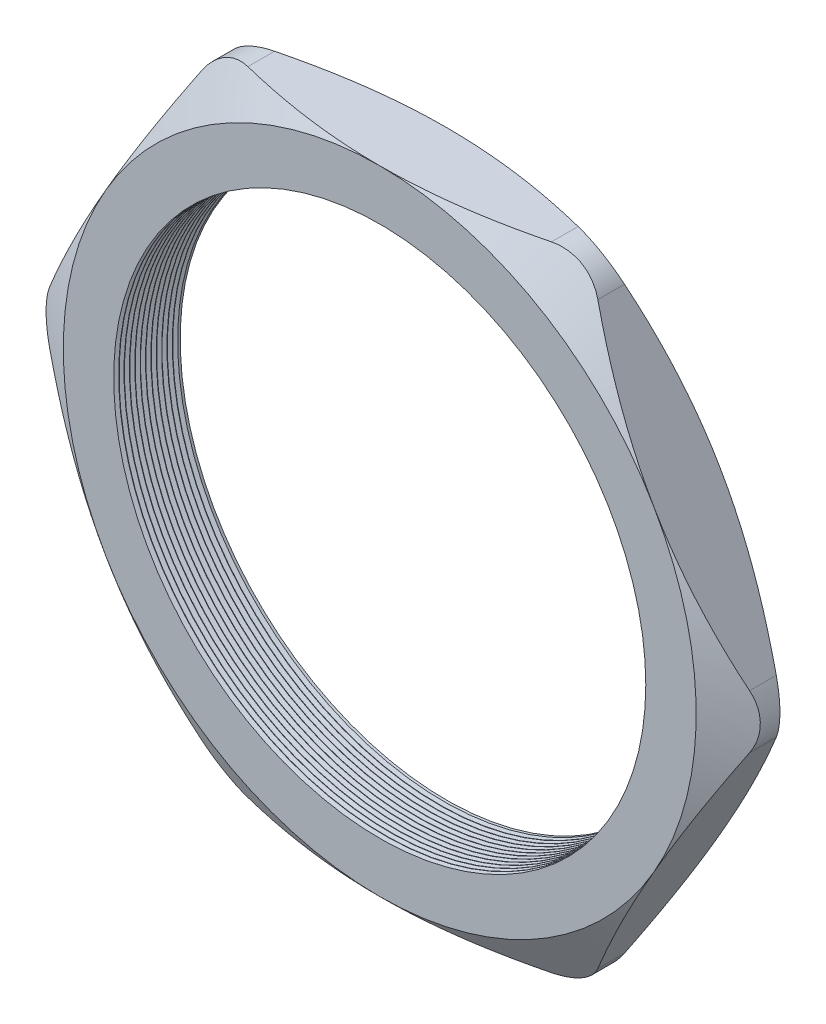
from build123d import *

# Parameters (mm, degrees)
SKETCH1_R          = 31.496
EXTRUDE1_DEPTH     = 7.874
SKETCH2_OUTSIDE_W  = 142.208
SKETCH2_OUTSIDE_H  = 130.616
SKETCH2_OUTSIDE_R  = 37.465
CUT_EXTRUDE1_DEPTH = 8.874
CUT_EXTRUDE1_DRAFT = -60
SKETCH3_OUTSIDE_W  = 142.208
SKETCH3_OUTSIDE_H  = 130.616
SKETCH3_OUTSIDE_R  = 37.465
CUT_EXTRUDE2_DEPTH = 8.874
CUT_EXTRUDE2_DRAFT = -60
FILLET1_R          = 6.35
LPATTERN1_COUNT    = 12
LPATTERN1_PITCH    = 0.635


with BuildPart() as part:
    # Sketch1 → Extrude1 (new body)
    with BuildSketch(Plane.XY):
        Polygon((-43.26085567, 0), (-21.630427835, -37.465), (21.630427835, -37.465), (43.26085567, 0), (21.630427835, 37.465), (-21.630427835, 37.465), align=None)
        Circle(SKETCH1_R, mode=Mode.SUBTRACT)
    extrude(amount=EXTRUDE1_DEPTH)


with BuildPart() as cut_extrude1_tool:
    # Sketch2 outside → Cut-Extrude1 (with draft: the straight prism first)
    with BuildSketch(Plane.XY.offset(7.874)):
        Rectangle(SKETCH2_OUTSIDE_W, SKETCH2_OUTSIDE_H)
        Circle(SKETCH2_OUTSIDE_R, mode=Mode.SUBTRACT)
    extrude(amount=-CUT_EXTRUDE1_DEPTH)
    # Cut-Extrude1: the draft: its side faces are tilted about the plane it starts from
    cut_extrude1_sides = [cut_extrude1_tool.faces().sort_by_distance(p)[0] for p in [
        (0, -65.308, 3.437),
        (71.104, 0, 3.437),
        (0, 65.308, 3.437),
        (-71.104, 0, 3.437),
        (-37.465, 0, 3.437),
    ]]
    draft(cut_extrude1_sides, Plane.XY.offset(7.874), CUT_EXTRUDE1_DRAFT)


with BuildPart() as part_1:
    add(part.part)

    # Cut-Extrude1: cut by cut_extrude1_tool
    add(cut_extrude1_tool.part, mode=Mode.SUBTRACT)


with BuildPart() as cut_extrude2_tool:
    # Sketch3 outside → Cut-Extrude2 (with draft: the straight prism first)
    with BuildSketch(Plane(origin=(0, 0, 0), x_dir=(-1, 0, 0), z_dir=(0, 0, -1))):
        Rectangle(SKETCH3_OUTSIDE_W, SKETCH3_OUTSIDE_H)
        Circle(SKETCH3_OUTSIDE_R, mode=Mode.SUBTRACT)
    extrude(amount=-CUT_EXTRUDE2_DEPTH)
    # Cut-Extrude2: the draft: its side faces are tilted about the plane it starts from
    cut_extrude2_sides = [cut_extrude2_tool.faces().sort_by_distance(p)[0] for p in [
        (0, -65.308, 4.437),
        (-71.104, 0, 4.437),
        (0, 65.308, 4.437),
        (71.104, 0, 4.437),
        (37.465, 0, 4.437),
    ]]
    draft(cut_extrude2_sides, Plane(origin=(0, 0, 0), x_dir=(-1, 0, 0), z_dir=(0, 0, -1)), CUT_EXTRUDE2_DRAFT)


with BuildPart() as part_2:
    add(part_1.part)

    # Cut-Extrude2: cut by cut_extrude2_tool
    add(cut_extrude2_tool.part, mode=Mode.SUBTRACT)

    # Fillet1
    fillet1_edges = [part_2.edges().sort_by_distance(p)[0] for p in [
        (43.26085567, 0, 3.937),
        (21.630427835, -37.465, 3.937),
        (-21.630427835, -37.465, 3.937),
        (-43.26085567, 0, 3.937),
        (-21.630427835, 37.465, 3.937),
        (21.630427835, 37.465, 3.937),
    ]]
    fillet(fillet1_edges, radius=FILLET1_R)

    # Sketch4 → Cut-Revolve1 (revolve, cut)
    with BuildSketch(Plane(origin=(0, 0, 0), x_dir=(1, 0, 0), z_dir=(0, 1, 0)), mode=Mode.PRIVATE) as cut_revolve1_sk:
        Polygon((-31.496, -7.874), (-31.496, -7.287412127), (-32.004, -7.580706063), align=None)
    cut_revolve1 = revolve(cut_revolve1_sk.sketch.rotate(Axis((0, 0, 0), (0, 0, 1)), 180), axis=Axis((0, 0, 0), (0, 0, 1)), mode=Mode.SUBTRACT)  # turned: the seam where the file's is

    # LPattern1: Cut-Revolve1 ×12
    with Locations(*[(0, 0, -i * LPATTERN1_PITCH) for i in range(1, LPATTERN1_COUNT)]):
        add(cut_revolve1, mode=Mode.SUBTRACT)


solid = part_2.part
